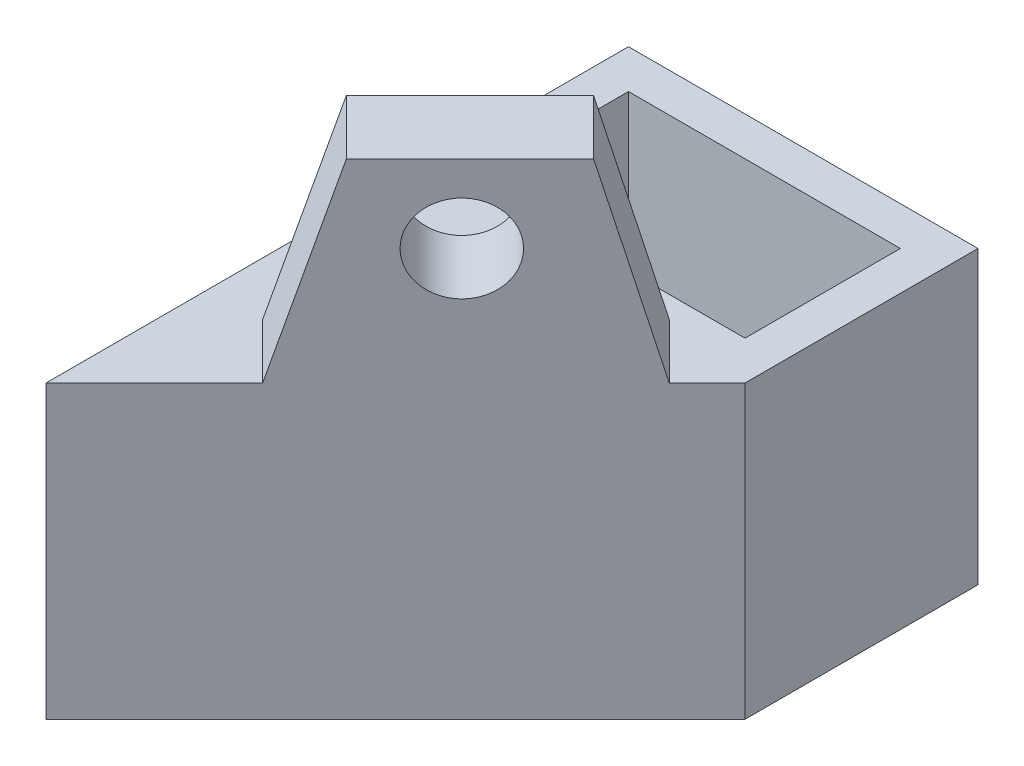
from build123d import *

# Parameters (mm, degrees)
SKETCH_1_W          = 14
SKETCH_1_H          = 8
EXTRUDE_1_DEPTH     = 15
EXTRUDE_2_DEPTH     = 10
SKETCH_4_R          = 2.25
CUT_EXTRUDE_1_DEPTH = 5.5
EXTRUDE_3_DEPTH     = 4


with BuildPart() as part:
    # 草图1 → 凸台-拉伸1 (new body)
    with BuildSketch(Plane(origin=(0, 0, 0), x_dir=(1, 0, 0), z_dir=(0, 1, 0))):
        Polygon((0, 0), (0, 10), (18, 10), (18, -2), (0, -20), align=None)
        with Locations((9, 4)):
            Rectangle(SKETCH_1_W, SKETCH_1_H, mode=Mode.SUBTRACT)
    extrude(amount=EXTRUDE_1_DEPTH)

    # 草图2 → 凸台-拉伸2 (add)
    with BuildSketch(Plane(origin=(0, 15, 0), x_dir=(1, 0, 0), z_dir=(0, 1, 0))):
        Polygon((11.272196348, -3.070949403), (14.100623473, -5.899376527), (7.734731659, -12.265268341), (4.906304534, -9.436841216), align=None)
    extrude(amount=EXTRUDE_2_DEPTH)

    # 草图4 → 切除-拉伸1 (cut)
    with BuildSketch(Plane(origin=(7.171572875, 0, 7.171572875), x_dir=(-0.707106781, 0, 0.707106781), z_dir=(-0.707106781, 0, -0.707106781))):
        with Locations((-1, 21)):
            Circle(SKETCH_4_R)
    extrude(amount=-CUT_EXTRUDE_1_DEPTH, mode=Mode.SUBTRACT)

    # 草图5 → 凸台-拉伸3 (add)
    with BuildSketch(Plane(origin=(10, 0, 10), x_dir=(0.707106781, 0, -0.707106781), z_dir=(0.707106781, 0, 0.707106781))):
        Polygon((5.799157329, 25), (5.799157329, 15), (8.556432914, 15), align=None)
        Polygon((-3.20357321, 25), (-3.20357321, 15), (-6.25343363, 15), align=None)
    extrude(amount=-EXTRUDE_3_DEPTH)


solid = part.part
